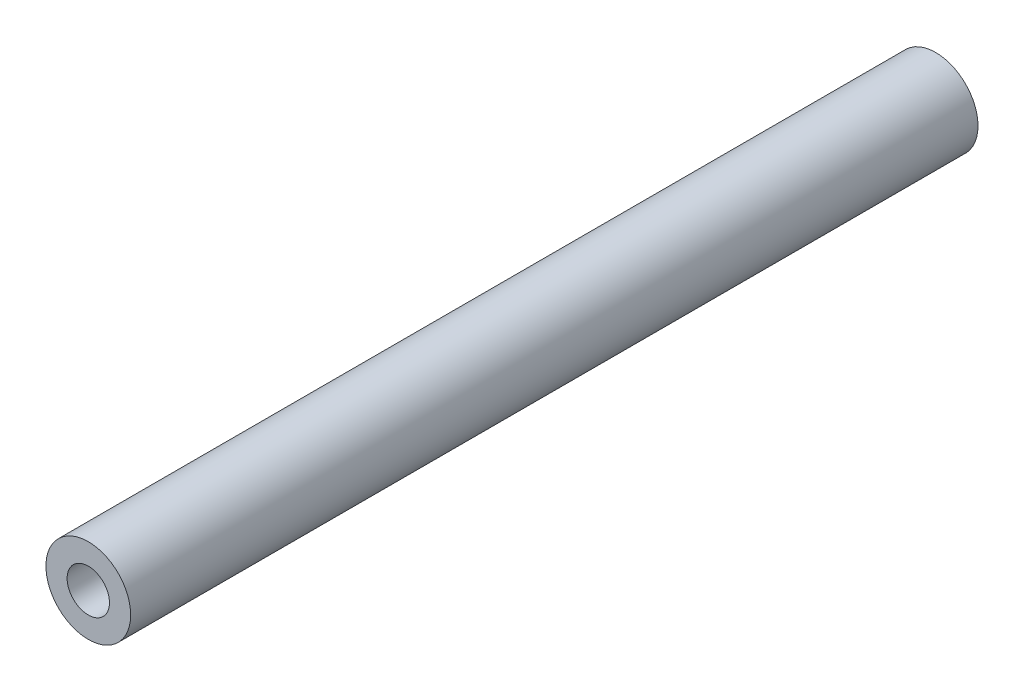
from build123d import *

# Parameters (mm, degrees)
SKETCH_1_R         = 2.5
EXTRUDE_1_DEPTH    = 50
HOLE_WIZARD_M3_1_D = 2.5


with BuildPart() as part:
    # 草图1 → 凸台-拉伸1 (new body)
    with BuildSketch(Plane.XY):
        Circle(SKETCH_1_R)
    extrude(amount=EXTRUDE_1_DEPTH)

    # M3 螺纹孔1 (through all)
    with Locations(Plane.XY.offset(50)):
        with Locations((0, 0)):
            Hole(HOLE_WIZARD_M3_1_D / 2)


solid = part.part
